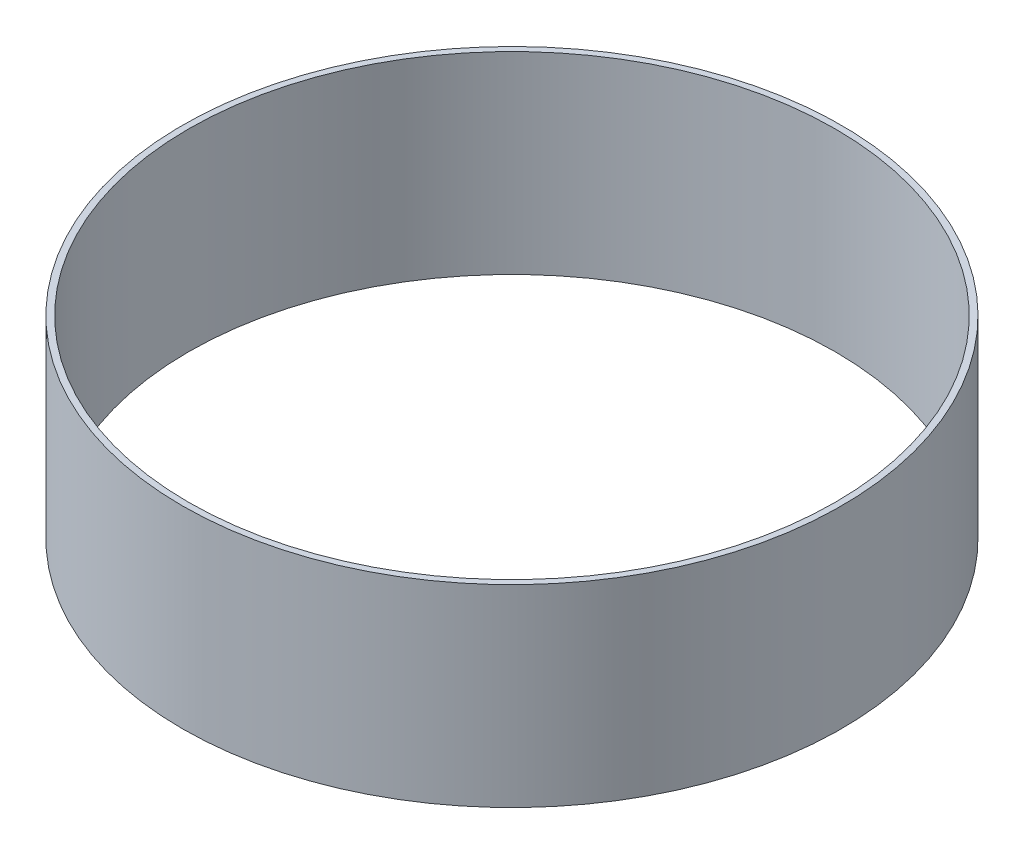
from build123d import *

# Parameters (mm, degrees)
SKETCH1_R           = 33.0835
SKETCH1_R_2         = 32.4612
BOSS_EXTRUDE1_DEPTH = 19.3802


with BuildPart() as part:
    # Sketch1 → Boss-Extrude1 (new body)
    with BuildSketch(Plane(origin=(0, 0, 0), x_dir=(1, 0, 0), z_dir=(0, 1, 0))):
        Circle(SKETCH1_R)
        Circle(SKETCH1_R_2, mode=Mode.SUBTRACT)
    extrude(amount=BOSS_EXTRUDE1_DEPTH)


solid = part.part
